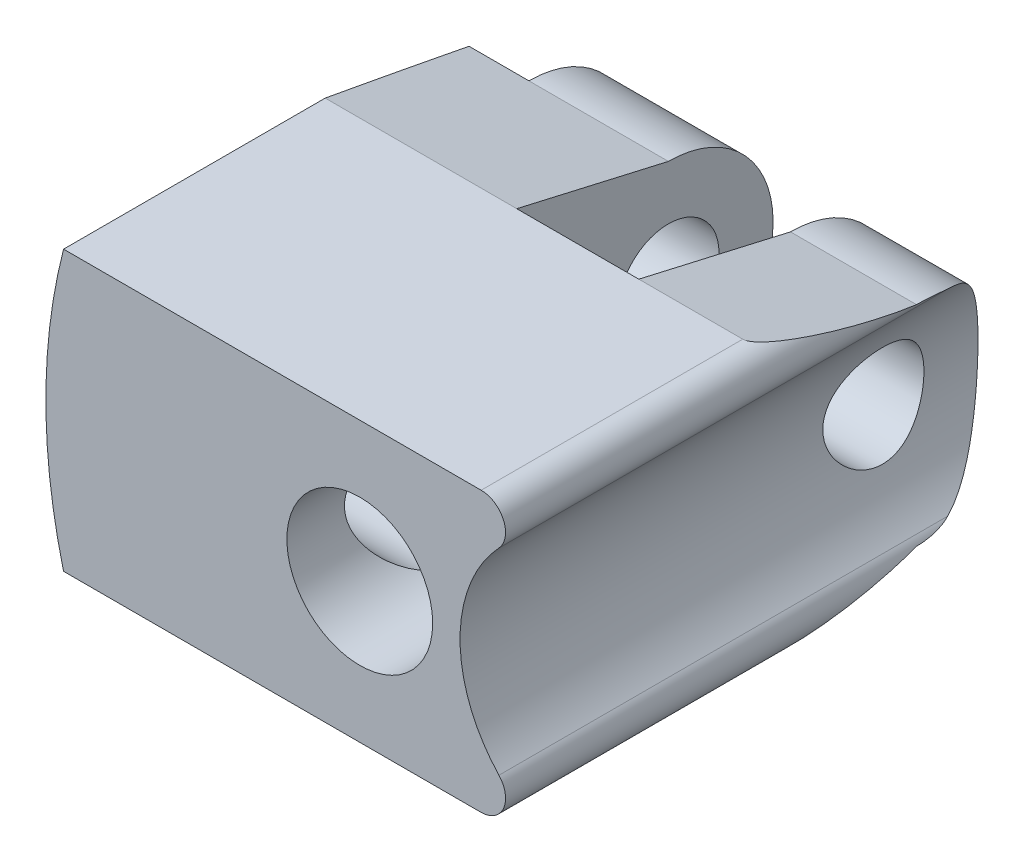
from build123d import *

# Parameters (mm, degrees)
SCHIZZO1_R                           = 2.09
ESTRUSIONE_ESTRUSIONE1_DEPTH         = 15
SCHIZZO5_W                           = 3.5
SCHIZZO5_H                           = 7.5
TAGLIO_ESTRUSIONE4_DEPTH             = 9
ESTRUSIONE_ESTRUSIONE2_REACH         = 7.492
SCHIZZO6_W                           = 6
SCHIZZO6_H                           = 8
SCHIZZO7_R                           = 1.45
TAGLIO_ESTRUSIONE5_DEPTH             = 9.992075583
TAGLIO_ESTRUSIONE5_DEPTH_BACK        = 7.000142198
SCHIZZO7_4_R                         = 1.85
TAGLIO_ESTRUSIONE6_DEPTH             = 7.000142323
TAGLIO_ESTRUSIONE6_DIRECTION_2_REACH = 10.992
RACCORDO1_R                          = 0.7
RACCORDO2_R                          = 0.7
TAGLIO_ESTRUSIONE7_DEPTH             = 8.179825842
TAGLIO_ESTRUSIONE7_DEPTH_BACK        = 7.000142323
TAGLIO_ESTRUSIONE9_START             = -4
SCHIZZO9_R                           = 3
TAGLIO_ESTRUSIONE9_DEPTH             = 3.000142323


with BuildPart() as part:
    # Schizzo1 → Estrusione-Estrusione1 (new body)
    with BuildSketch(Plane.XY):
        with BuildLine():
            Line((5.992217781, -4), (-8.491933385, -4))
            ThreePointArc((-8.491933385, -4), (-9, 0), (-8.491933385, 4))
            Line((-8.491933385, 4), (5.992217781, 4))
            ThreePointArc((5.992217781, 4), (2.875, 0), (5.992217781, -4))
        make_face()
        Circle(SCHIZZO1_R, mode=Mode.SUBTRACT)
    extrude(amount=ESTRUSIONE_ESTRUSIONE1_DEPTH)

    # Schizzo5 → Taglio-Estrusione4 (cut, through all)
    with BuildSketch(Plane.XZ.offset(4)):
        with Locations((-1.249857802, 3.75)):
            Rectangle(SCHIZZO5_W, SCHIZZO5_H)
    extrude(amount=-TAGLIO_ESTRUSIONE4_DEPTH, mode=Mode.SUBTRACT)

    # Schizzo6 → Estrusione-Estrusione2 (add, up to next)
    with BuildSketch(Plane.ZY.offset(-0.500142198), mode=Mode.PRIVATE) as estrusione_estrusione2_sk1:
        with Locations((3, 0)):
            Rectangle(SCHIZZO6_W, SCHIZZO6_H)
    estrusione_estrusione2_tool1 = extrude(estrusione_estrusione2_sk1.sketch, amount=-ESTRUSIONE_ESTRUSIONE2_REACH, mode=Mode.PRIVATE) - part.part
    add(estrusione_estrusione2_tool1.solids().sort_by_distance((0.500142, 0, 3))[0])

    # Schizzo7 → Taglio-Estrusione5 (cut, two sides)
    with BuildSketch(Plane(origin=(-2.999857802, 0, 0), x_dir=(0, 0, -1), z_dir=(1, 0, 0))) as taglio_estrusione5_sk:
        with Locations((-3.15, 0)):
            Circle(SCHIZZO7_R)
    extrude(amount=TAGLIO_ESTRUSIONE5_DEPTH, mode=Mode.SUBTRACT)
    extrude(taglio_estrusione5_sk.sketch, amount=-TAGLIO_ESTRUSIONE5_DEPTH_BACK, mode=Mode.SUBTRACT)

    # Schizzo7_4 → Taglio-Estrusione6 (cut)
    with BuildSketch(Plane(origin=(-2.999857802, 0, 0), x_dir=(0, 0, -1), z_dir=(1, 0, 0))):
        with Locations((-11.5, 0)):
            Circle(SCHIZZO7_4_R)
    extrude(amount=-TAGLIO_ESTRUSIONE6_DEPTH, mode=Mode.SUBTRACT)

    # Schizzo7_4 → Taglio-Estrusione6 direction 2 (cut, up to next)
    with BuildSketch(Plane(origin=(-2.999857802, 0, 0), x_dir=(0, 0, -1), z_dir=(1, 0, 0)), mode=Mode.PRIVATE) as taglio_estrusione6_direction_2_sk1:
        with Locations((-11.5, 0)):
            Circle(SCHIZZO7_4_R)
    taglio_estrusione6_direction_2_tool1 = extrude(taglio_estrusione6_direction_2_sk1.sketch, amount=TAGLIO_ESTRUSIONE6_DIRECTION_2_REACH, mode=Mode.PRIVATE) & part.part
    add(taglio_estrusione6_direction_2_tool1.solids().sort_by_distance((-2.999858, 0, 11.5))[0], mode=Mode.SUBTRACT)

    # Raccordo1
    raccordo1_edges = [part.edges().sort_by_distance(p)[0] for p in [
        (5.992217781, 4, 7.5),
    ]]
    fillet(raccordo1_edges, radius=RACCORDO1_R)

    # Raccordo2
    raccordo2_edges = [part.edges().sort_by_distance(p)[0] for p in [
        (5.992217781, -4, 7.5),
    ]]
    fillet(raccordo2_edges, radius=RACCORDO2_R)

    # Schizzo8 → Taglio-Estrusione7 (cut, two sides)
    with BuildSketch(Plane(origin=(-2.999857802, 0, 0), x_dir=(0, 0, -1), z_dir=(1, 0, 0))) as taglio_estrusione7_sk:
        with BuildLine():
            Line((-3.15, -4), (0, -4))
            Line((0, -4), (0, 4))
            Line((0, 4), (-3.15, 4))
            Line((-3.15, 4), (-7.5, 4))
            Line((-7.5, 4), (-3.15, 3))
            ThreePointArc((-3.15, 3), (-0.15, 0), (-3.15, -3))
            Line((-3.15, -3), (-7.5, -4))
            Line((-7.5, -4), (-3.15, -4))
        make_face()
    extrude(amount=TAGLIO_ESTRUSIONE7_DEPTH, mode=Mode.SUBTRACT)
    extrude(taglio_estrusione7_sk.sketch, amount=-TAGLIO_ESTRUSIONE7_DEPTH_BACK, mode=Mode.SUBTRACT)

    # Schizzo9 → Taglio-Estrusione9 (cut, through all)
    with BuildSketch(Plane(origin=(-2.999857802, 0, 0), x_dir=(0, 0, -1), z_dir=(1, 0, 0)).offset(TAGLIO_ESTRUSIONE9_START)):
        with Locations((-3.15, 0)):
            Circle(SCHIZZO9_R)
    extrude(amount=-TAGLIO_ESTRUSIONE9_DEPTH, mode=Mode.SUBTRACT)


solid = part.part
